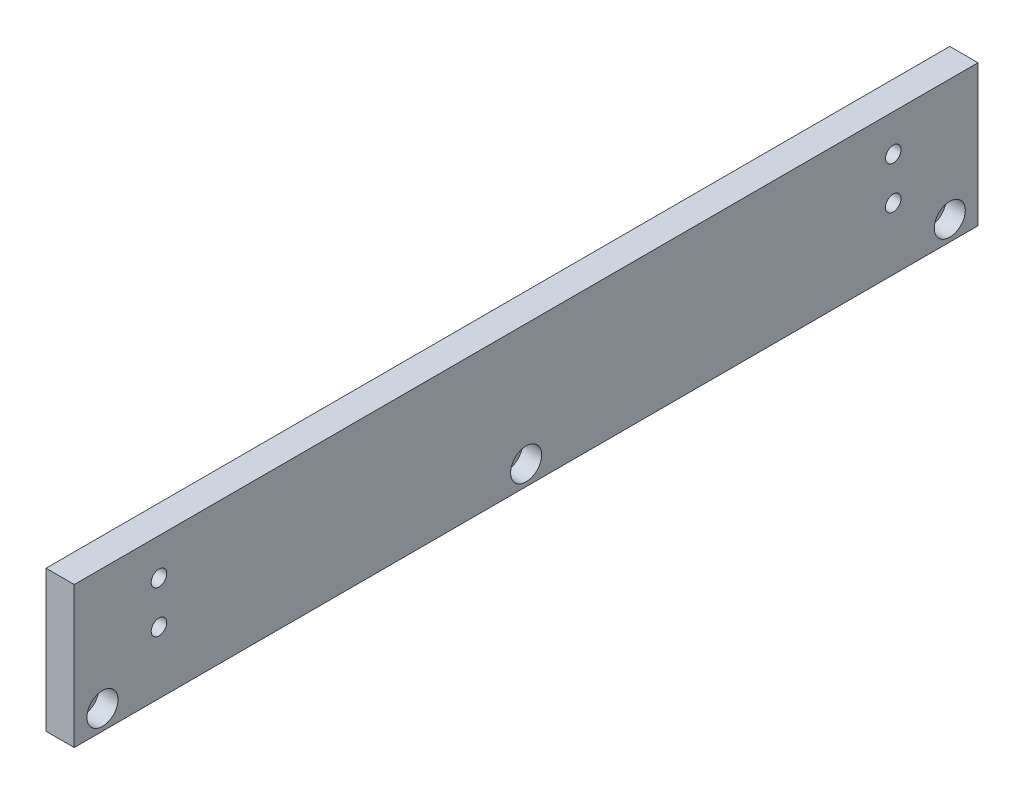
from build123d import *

# Parameters (mm, degrees)
SKETCH_1_W                  = 10
SKETCH_1_H                  = 50
EXTRUDE_1_DEPTH             = 320
HOLE_WIZARD_2_D             = 6.6
HOLE_WIZARD_2_CBORE_D       = 11
HOLE_WIZARD_2_CBORE_DEPTH   = 6.8
HOLE_WIZARD_2_2_D           = 5.5
HOLE_WIZARD_2_2_CBORE_D     = 10
HOLE_WIZARD_2_2_CBORE_DEPTH = 5.7


with BuildPart() as part:
    # 草图1 → 凸台-拉伸1 (new body)
    with BuildSketch(Plane.XY):
        with Locations((5, 25)):
            Rectangle(SKETCH_1_W, SKETCH_1_H)
    extrude(amount=EXTRUDE_1_DEPTH)

    # Hole Wizard 2 (through all)
    with Locations(Plane(origin=(10, 7, 310), x_dir=(0, 0, 1), z_dir=(1, 0, 0))):
        with Locations((0, 0), (-150, 0), (-300, 0)):
            CounterBoreHole(HOLE_WIZARD_2_D / 2, HOLE_WIZARD_2_CBORE_D / 2, HOLE_WIZARD_2_CBORE_DEPTH)

    # Hole Wizard 2 2 (through all)
    with Locations(Plane(origin=(0, 37, 290), x_dir=(0, 0, -1), z_dir=(-1, 0, 0))):
        with Locations((0, 0), (0, 15), (260, 0), (260, 15)):
            CounterBoreHole(HOLE_WIZARD_2_2_D / 2, HOLE_WIZARD_2_2_CBORE_D / 2, HOLE_WIZARD_2_2_CBORE_DEPTH)


solid = part.part
